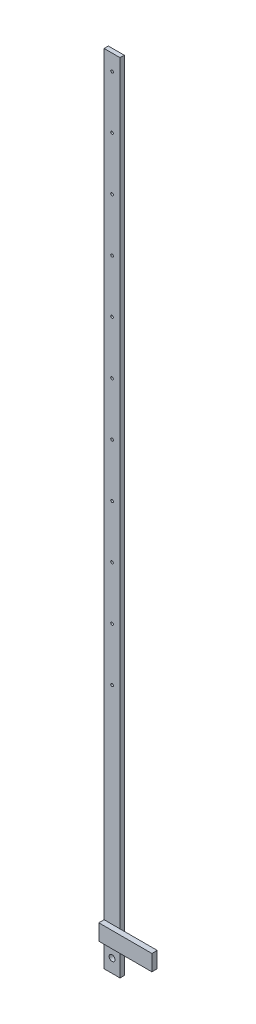
from build123d import *

# Parameters (mm, degrees)
SKETCH1_W           = 3
SKETCH1_H           = 150
SKETCH1_R           = 0.55
SKETCH1_R_2         = 0.25
BOSS_EXTRUDE3_DEPTH = 0.8
SKETCH2_W           = 10
SKETCH2_H           = 3
BOSS_EXTRUDE4_DEPTH = 1


with BuildPart() as part:
    # Sketch1 → Boss-Extrude3 (new body)
    with BuildSketch(Plane.XY):
        with Locations((0, 72.5)):
            Rectangle(SKETCH1_W, SKETCH1_H)
        Circle(SKETCH1_R, mode=Mode.SUBTRACT)
        with Locations((0, 144.5)):
            Circle(SKETCH1_R_2, mode=Mode.SUBTRACT)
        with Locations((0, 134.5)):
            Circle(SKETCH1_R_2, mode=Mode.SUBTRACT)
        with Locations((0, 124.5)):
            Circle(SKETCH1_R_2, mode=Mode.SUBTRACT)
        with Locations((0, 114.5)):
            Circle(SKETCH1_R_2, mode=Mode.SUBTRACT)
        with Locations((0, 104.5)):
            Circle(SKETCH1_R_2, mode=Mode.SUBTRACT)
        with Locations((0, 64.5)):
            Circle(SKETCH1_R_2, mode=Mode.SUBTRACT)
        with Locations((0, 54.5)):
            Circle(SKETCH1_R_2, mode=Mode.SUBTRACT)
        with Locations((0, 94.5)):
            Circle(SKETCH1_R_2, mode=Mode.SUBTRACT)
        with Locations((0, 84.5)):
            Circle(SKETCH1_R_2, mode=Mode.SUBTRACT)
        with Locations((0, 74.5)):
            Circle(SKETCH1_R_2, mode=Mode.SUBTRACT)
        with Locations((0, 44.5)):
            Circle(SKETCH1_R_2, mode=Mode.SUBTRACT)
    extrude(amount=BOSS_EXTRUDE3_DEPTH)

    # Sketch2 → Boss-Extrude4 (add)
    with BuildSketch(Plane.XY.offset(0.8)):
        with Locations((3.5, 4)):
            Rectangle(SKETCH2_W, SKETCH2_H)
    extrude(amount=BOSS_EXTRUDE4_DEPTH)


solid = part.part
